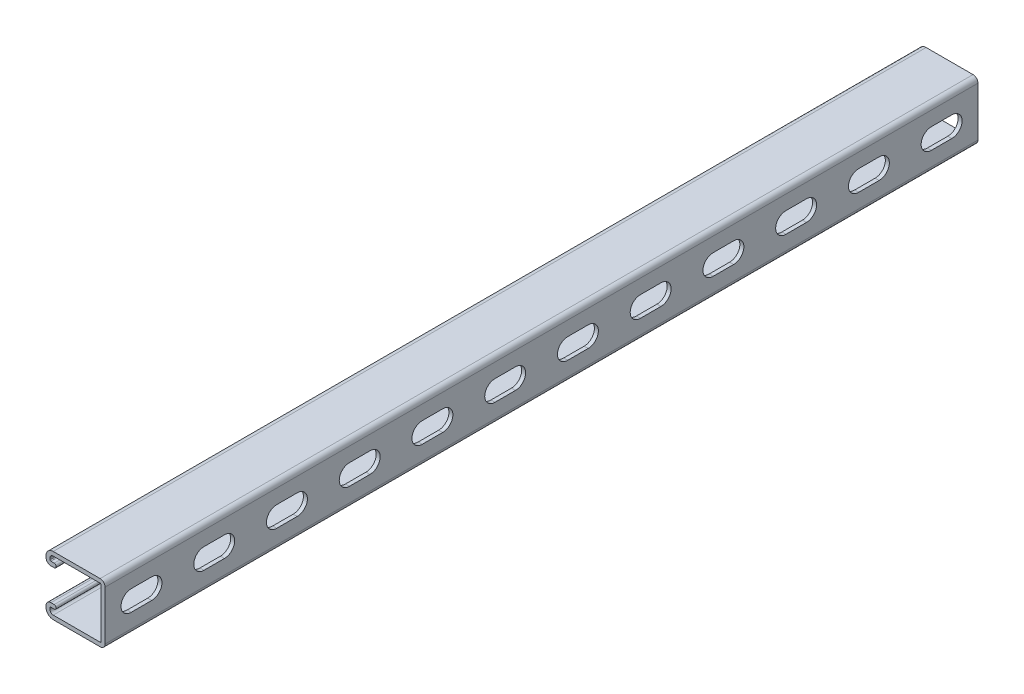
from build123d import *

# Parameters (mm, degrees)
BOSS_EXTRUDE1_DEPTH = 609.6
CUT_EXTRUDE1_DEPTH  = 2.794
LPATTERN1_COUNT     = 12
LPATTERN1_PITCH     = 50.8


with BuildPart() as part:
    # Sketch1 → Boss-Extrude1 (new body)
    with BuildSketch(Plane.XY):
        with BuildLine():
            Line((-36.22675, 20.6375), (-3.46075, 20.6375))
            ThreePointArc((-3.46075, 20.6375), (-1.013630207, 19.623869793), (0, 17.17675))
            Line((0, 17.17675), (0, -17.17675))
            ThreePointArc((0, -17.17675), (-1.013630207, -19.623869793), (-3.46075, -20.6375))
            Line((-3.46075, -20.6375), (-36.22675, -20.6375))
            ThreePointArc((-36.22675, -20.6375), (-39.796401808, -19.158901808), (-41.275, -15.58925))
            Line((-41.275, -15.58925), (-41.275, -14.57325))
            ThreePointArc((-41.275, -14.57325), (-40.261369793, -12.126130207), (-37.81425, -11.1125))
            Line((-37.81425, -11.1125), (-35.5346, -11.1125))
            ThreePointArc((-35.5346, -11.1125), (-34.1376, -12.5095), (-35.5346, -13.9065))
            Line((-35.5346, -13.9065), (-37.81425, -13.9065))
            ThreePointArc((-37.81425, -13.9065), (-38.285713446, -14.101786554), (-38.481, -14.57325))
            Line((-38.481, -14.57325), (-38.481, -15.58925))
            ThreePointArc((-38.481, -15.58925), (-37.820745461, -17.183245461), (-36.22675, -17.8435))
            Line((-36.22675, -17.8435), (-3.46075, -17.8435))
            ThreePointArc((-3.46075, -17.8435), (-2.989286554, -17.648213446), (-2.794, -17.17675))
            Line((-2.794, -17.17675), (-2.794, 17.17675))
            ThreePointArc((-2.794, 17.17675), (-2.989286554, 17.648213446), (-3.46075, 17.8435))
            Line((-3.46075, 17.8435), (-36.22675, 17.8435))
            ThreePointArc((-36.22675, 17.8435), (-37.820745461, 17.183245461), (-38.481, 15.58925))
            Line((-38.481, 15.58925), (-38.481, 14.57325))
            ThreePointArc((-38.481, 14.57325), (-38.285713446, 14.101786554), (-37.81425, 13.9065))
            Line((-37.81425, 13.9065), (-35.5346, 13.9065))
            ThreePointArc((-35.5346, 13.9065), (-34.1376, 12.5095), (-35.5346, 11.1125))
            Line((-35.5346, 11.1125), (-37.81425, 11.1125))
            ThreePointArc((-37.81425, 11.1125), (-40.261369793, 12.126130207), (-41.275, 14.57325))
            Line((-41.275, 14.57325), (-41.275, 15.58925))
            ThreePointArc((-41.275, 15.58925), (-39.796401808, 19.158901808), (-36.22675, 20.6375))
        make_face()
    extrude(amount=-BOSS_EXTRUDE1_DEPTH)

    # Sketch2 → Cut-Extrude1 (cut)
    with BuildSketch(Plane(origin=(0, 0, 0), x_dir=(0, 0, -1), z_dir=(1, 0, 0))):
        with BuildLine():
            Line((18.25625, 7.14375), (32.54375, 7.14375))
            ThreePointArc((32.54375, 7.14375), (39.6875, 0), (32.54375, -7.14375))
            Line((32.54375, -7.14375), (18.25625, -7.14375))
            ThreePointArc((18.25625, -7.14375), (11.1125, 0), (18.25625, 7.14375))
        make_face()
    cut_extrude1 = extrude(amount=-CUT_EXTRUDE1_DEPTH, mode=Mode.SUBTRACT)

    # LPattern1: Cut-Extrude1 ×12
    with Locations(*[(0, 0, -i * LPATTERN1_PITCH) for i in range(1, LPATTERN1_COUNT)]):
        add(cut_extrude1, mode=Mode.SUBTRACT)


solid = part.part
